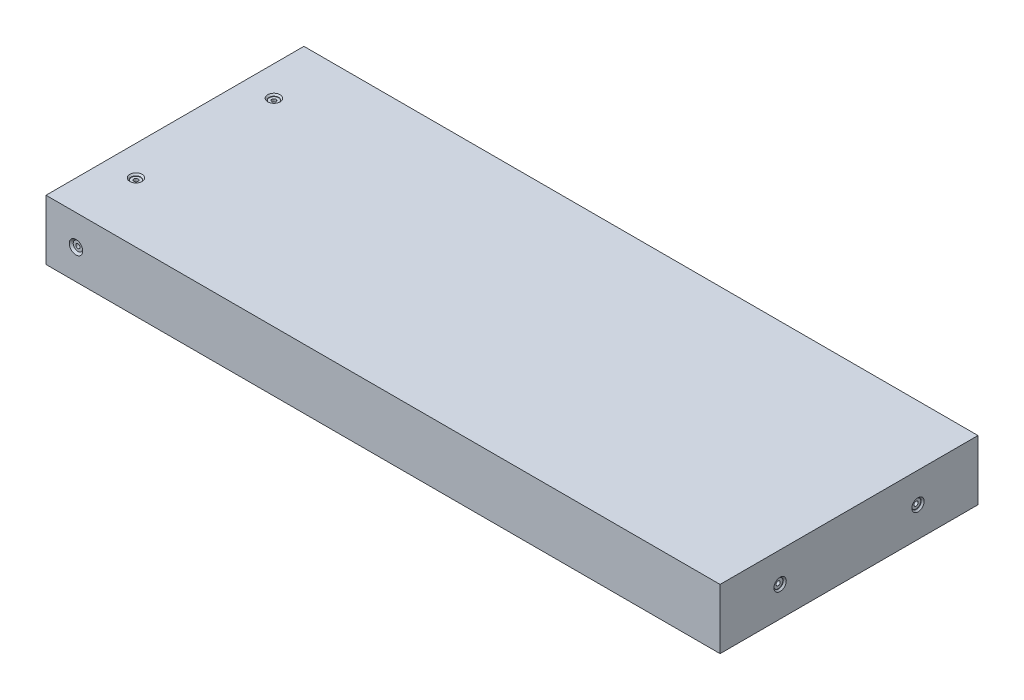
from build123d import *

# Parameters (mm, degrees)
SKETCH1_W                                   = 285.4
SKETCH1_H                                   = 109.2
BOSS_EXTRUDE1_DEPTH                         = 25.4
CBORE_FOR_0_BINDING_HEAD_MACHINE_SC_2_COUNT = 2
CBORE_FOR_0_BINDING_HEAD_MACHINE_SC_2_PITCH = 58.405486046
CBORE_FOR_0_BINDING_HEAD_MACHINE_SC_3_COUNT = 2
CBORE_FOR_0_BINDING_HEAD_MACHINE_SC_3_PITCH = 58.4
LPATTERN1_COUNT                             = 2
LPATTERN1_PITCH                             = 58.4


with BuildPart() as part:
    # Sketch1 → Boss-Extrude1 (new body)
    with BuildSketch(Plane(origin=(0, 0, 0), x_dir=(1, 0, 0), z_dir=(0, 1, 0))):
        Rectangle(SKETCH1_W, SKETCH1_H)
    extrude(amount=BOSS_EXTRUDE1_DEPTH)

    # Sketch3 → CBORE for #0 Binding Head Machine Screw1 (revolve, cut)
    with BuildSketch(Plane(origin=(-130, 12.7, 54.6), x_dir=(0, -1, 0), z_dir=(1, 0, 0))):
        Polygon((0, 0), (0, 30.53416509), (0.889, 30), (0.889, 0.8128), (1.98501, 0.8128), (1.98501, 0.87249), (2.8575, 0), align=None)
    cbore_for_0_binding_head_machine_screw1 = revolve(axis=Axis((-130, 12.7, 60.95), (0, 0, -1)), mode=Mode.SUBTRACT)

    # Mirror1: CBORE for #0 Binding Head Machine Screw1 across plane
    add(cbore_for_0_binding_head_machine_screw1.mirror(Plane.XY), mode=Mode.SUBTRACT)

    # Sketch5 → CBORE for #0 Binding Head Machine Screw2 (revolve, cut)
    with BuildSketch(Plane(origin=(142.7, -45.7, 30), x_dir=(0, 0, -1), z_dir=(0, 1, 0))):
        Polygon((0, 0), (0, 30.53416509), (0.889, 30), (0.889, 0.8128), (1.98501, 0.8128), (1.98501, 0.635), (2.62001, 0), align=None)
    cbore_for_0_binding_head_machine_screw2 = revolve(axis=Axis((149.05, -45.7, 30), (-1, 0, 0)), mode=Mode.SUBTRACT)

    # CBORE for _0 Binding Head Machine Sc 2: CBORE for #0 Binding Head Machine Screw2 ×2
    with Locations(*[Vector(0, 0.99990607, -0.013705904) * (i * CBORE_FOR_0_BINDING_HEAD_MACHINE_SC_2_PITCH) for i in range(1, CBORE_FOR_0_BINDING_HEAD_MACHINE_SC_2_COUNT)]):
        add(cbore_for_0_binding_head_machine_screw2, mode=Mode.SUBTRACT)

    # Sketch7 → CBORE for #0 Binding Head Machine Screw3 (revolve, cut)
    with BuildSketch(Plane(origin=(-130, 25.4, -29.1995), x_dir=(0, 0, 1), z_dir=(1, 0, 0))):
        Polygon((0, 0), (0, 30.53416509), (0.889, 30), (0.889, 0.8128), (1.98501, 0.8128), (1.98501, 0.635), (2.62001, 0), align=None)
    cbore_for_0_binding_head_machine_screw3 = revolve(axis=Axis((-130, 31.75, -29.1995), (0, -1, 0)), mode=Mode.SUBTRACT)

    # CBORE for _0 Binding Head Machine Sc 3: CBORE for #0 Binding Head Machine Screw3 ×2
    with Locations(*[(0, 0, i * CBORE_FOR_0_BINDING_HEAD_MACHINE_SC_3_PITCH) for i in range(1, CBORE_FOR_0_BINDING_HEAD_MACHINE_SC_3_COUNT)]):
        add(cbore_for_0_binding_head_machine_screw3, mode=Mode.SUBTRACT)

    # LPattern1: CBORE for #0 Binding Head Machine Screw2 ×2
    with Locations(*[(0, 0, -i * LPATTERN1_PITCH) for i in range(1, LPATTERN1_COUNT)]):
        add(cbore_for_0_binding_head_machine_screw2, mode=Mode.SUBTRACT)

    # LPattern1 copy 1 sketch → LPattern1 copy 1 (revolve, cut)
    with BuildSketch(Plane(origin=(142.7, 12.7, -29.2005), x_dir=(0, 0, -1), z_dir=(0, 1, 0))):
        Polygon((0, 0), (0, 30.53416509), (0.889, 30), (0.889, 0.8128), (1.98501, 0.8128), (1.98501, 0.635), (2.62001, 0), align=None)
    revolve(axis=Axis((149.05, 12.7, -29.2005), (-1, 0, 0)), mode=Mode.SUBTRACT)


solid = part.part
